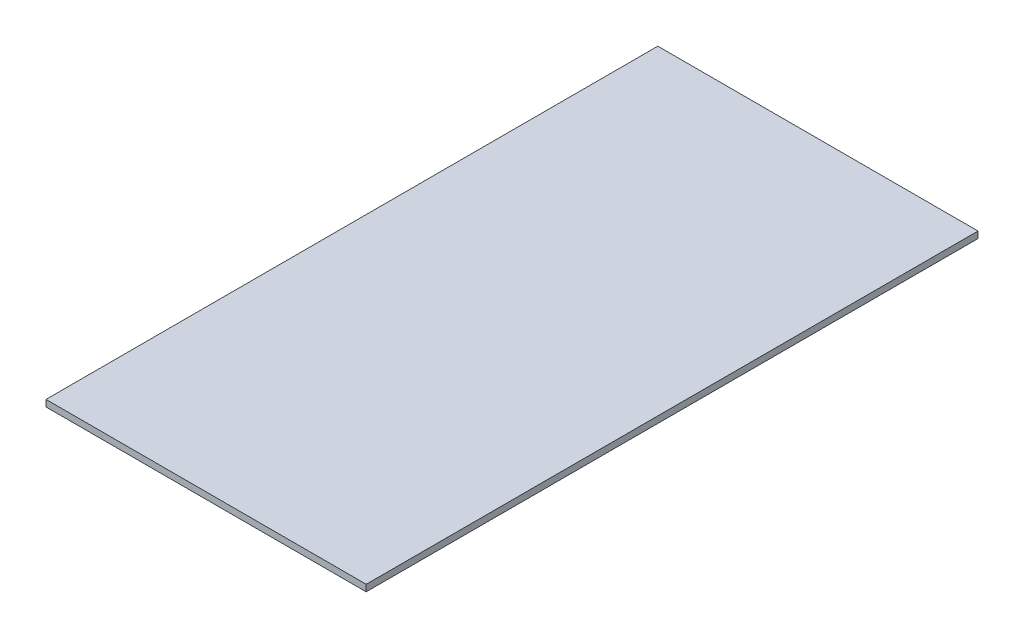
from build123d import *

# Parameters (mm, degrees)
SKETCH1_W           = 146.4056
SKETCH1_H           = 279.7556
BOSS_EXTRUDE1_DEPTH = 2.9972


with BuildPart() as part:
    # Sketch1 → Boss-Extrude1 (new body)
    with BuildSketch(Plane(origin=(0, 0, 0), x_dir=(1, 0, 0), z_dir=(0, 1, 0))):
        with Locations((73.2028, -139.8778)):
            Rectangle(SKETCH1_W, SKETCH1_H)
    extrude(amount=BOSS_EXTRUDE1_DEPTH)


solid = part.part
